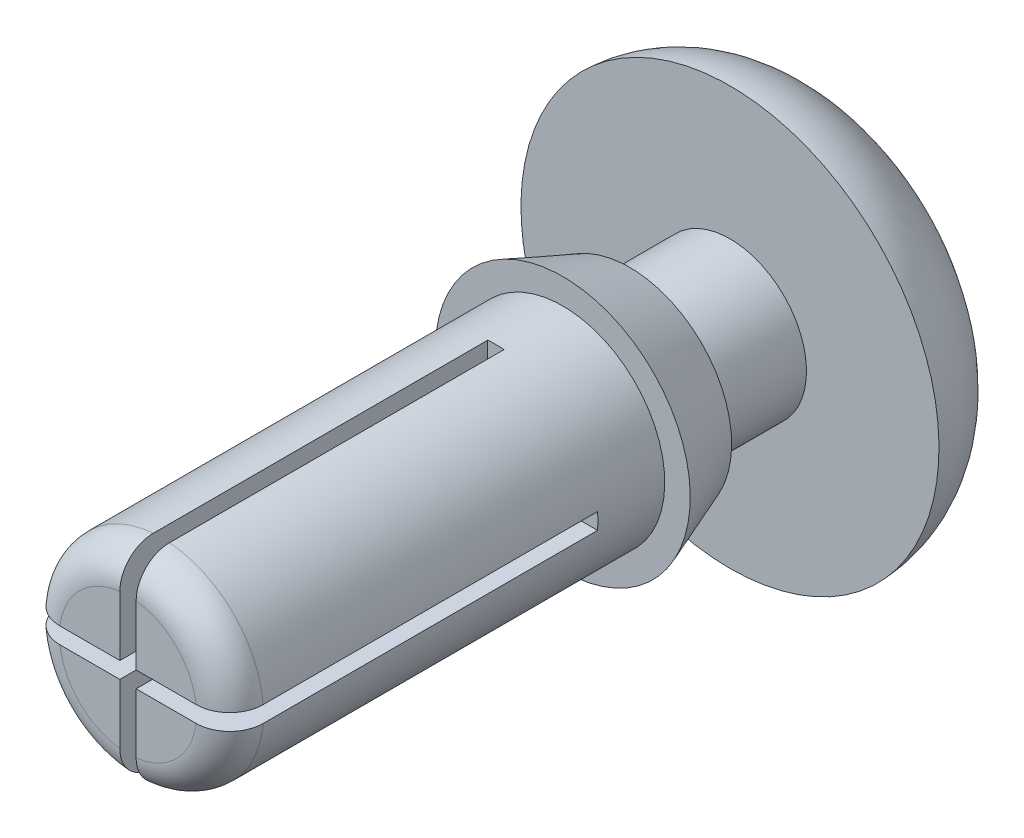
from build123d import *

# Parameters (mm, degrees)
SKETCH3_W          = 0.247904
SKETCH3_H          = 0.247904
CUT_EXTRUDE1_DEPTH = 5.588
FILLET1_R          = 0.508


with BuildPart() as part:
    # Sketch2 → Revolve1 (revolve)
    with BuildSketch(Plane(origin=(0, 0, 0), x_dir=(0, 0, -1), z_dir=(1, 0, 0))):
        with BuildLine():
            Line((2.54, 3.175), (2.54, 1.16205))
            Line((2.54, 1.16205), (1.016, 1.16205))
            Line((1.016, 1.16205), (1.016, 1.5494))
            Line((1.016, 1.5494), (0, 1.93675))
            Line((0, 1.93675), (0, 1.5494))
            Line((0, 1.5494), (-6.604, 1.5494))
            Line((-6.604, 1.5494), (-6.604, 0))
            Line((-6.604, 0), (4.064, 0))
            Line((4.064, 0), (4.064, 1.5875))
            ThreePointArc((4.064, 1.5875), (3.621333791, 2.687810439), (2.54, 3.175))
        make_face()
    revolve(axis=Axis((0, 0, 6.604), (0, 0, -1)))

    # Sketch3 → Cut-Extrude1 (cut)
    with BuildSketch(Plane.XY.offset(6.604)):
        with BuildLine():
            Line((0.123952, 3.172579534), (-0.123952, 3.172579534))
            Line((-0.123952, 3.172579534), (-0.123952, 1.544433962))
            ThreePointArc((-0.123952, 1.544433962), (0, 1.5494), (0.123952, 1.544433962))
            Line((0.123952, 1.544433962), (0.123952, 3.172579534))
        make_face()
        with BuildLine():
            ThreePointArc((0.123952, 1.544433962), (0, 1.5494), (-0.123952, 1.544433962))
            Line((-0.123952, 1.544433962), (-0.123952, 0.123952))
            Line((-0.123952, 0.123952), (0.123952, 0.123952))
            Line((0.123952, 0.123952), (0.123952, 1.544433962))
        make_face()
        with BuildLine():
            ThreePointArc((-1.544433962, -0.123952), (-1.5494, 0), (-1.544433962, 0.123952))
            Line((-1.544433962, 0.123952), (-3.172579534, 0.123952))
            Line((-3.172579534, 0.123952), (-3.172579534, -0.123952))
            Line((-3.172579534, -0.123952), (-1.544433962, -0.123952))
        make_face()
        with BuildLine():
            Line((3.172579534, 0.123952), (1.544433962, 0.123952))
            ThreePointArc((1.544433962, 0.123952), (1.548157993, 0.06202572), (1.5494, 0))
            ThreePointArc((1.5494, 0), (1.548157993, -0.06202572), (1.544433962, -0.123952))
            Line((1.544433962, -0.123952), (3.172579534, -0.123952))
            Line((3.172579534, -0.123952), (3.172579534, 0.123952))
        make_face()
        with BuildLine():
            Line((0.123952, -0.123952), (-0.123952, -0.123952))
            Line((-0.123952, -0.123952), (-0.123952, -1.544433962))
            ThreePointArc((-0.123952, -1.544433962), (0, -1.5494), (0.123952, -1.544433962))
            Line((0.123952, -1.544433962), (0.123952, -0.123952))
        make_face()
        with BuildLine():
            Line((1.544433962, 0.123952), (0.123952, 0.123952))
            Line((0.123952, 0.123952), (0.123952, -0.123952))
            Line((0.123952, -0.123952), (1.544433962, -0.123952))
            ThreePointArc((1.544433962, -0.123952), (1.548157993, -0.06202572), (1.5494, 0))
            ThreePointArc((1.5494, 0), (1.548157993, 0.06202572), (1.544433962, 0.123952))
        make_face()
        with BuildLine():
            Line((-0.123952, -0.123952), (-0.123952, 0.123952))
            Line((-0.123952, 0.123952), (-1.544433962, 0.123952))
            ThreePointArc((-1.544433962, 0.123952), (-1.5494, 0), (-1.544433962, -0.123952))
            Line((-1.544433962, -0.123952), (-0.123952, -0.123952))
        make_face()
        Rectangle(SKETCH3_W, SKETCH3_H)
        with BuildLine():
            ThreePointArc((0.123952, -1.544433962), (0, -1.5494), (-0.123952, -1.544433962))
            Line((-0.123952, -1.544433962), (-0.123952, -3.172579534))
            Line((-0.123952, -3.172579534), (0.123952, -3.172579534))
            Line((0.123952, -3.172579534), (0.123952, -1.544433962))
        make_face()
    extrude(amount=-CUT_EXTRUDE1_DEPTH, mode=Mode.SUBTRACT)

    # Fillet1
    fillet1_edges = [part.edges().sort_by_distance(p)[0] for p in [
        (1.095591247, -1.095591247, 6.604),
        (1.095591247, 1.095591247, 6.604),
        (-1.095591247, 1.095591247, 6.604),
        (-1.095591247, -1.095591247, 6.604),
    ]]
    fillet(fillet1_edges, radius=FILLET1_R)


solid = part.part
